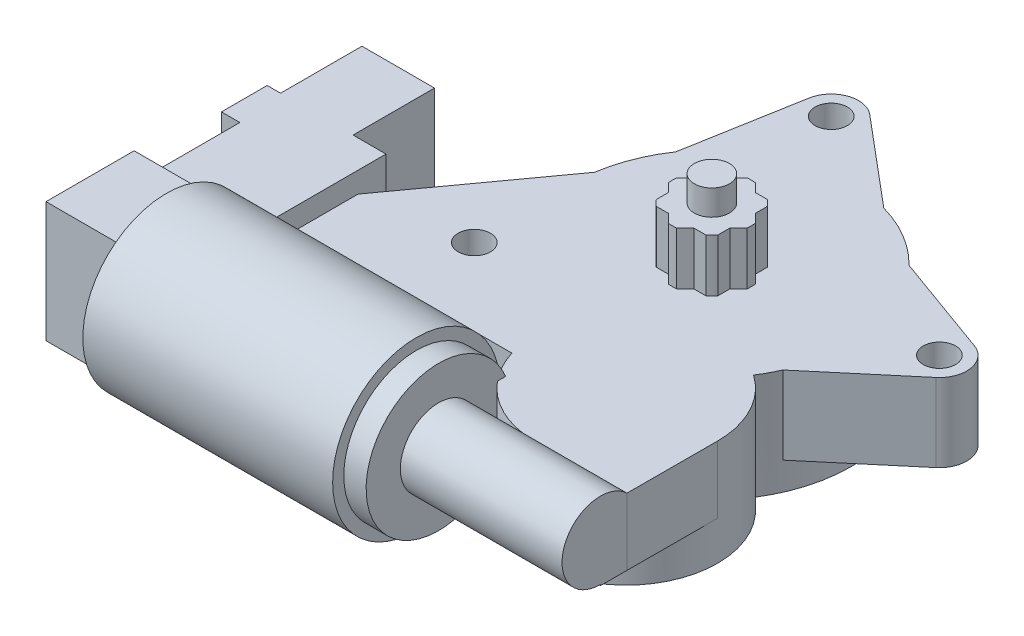
from build123d import *

# Parameters (mm, degrees)
SKETCH1_R                = 31.75
BOSS_EXTRUDE1_DEPTH      = 24.13
SKETCH2_R                = 20.828
BOSS_EXTRUDE2_DEPTH      = 24.13
SKETCH3_R                = 8.7249
BOSS_EXTRUDE3_DEPTH      = 35.56
BOSS_EXTRUDE3_DEPTH_BACK = 1.27
SKETCH4_R                = 16.51
BOSS_EXTRUDE4_DEPTH      = 5.08
SKETCH5_R                = 19.05
BOSS_EXTRUDE5_DEPTH      = 56.896
SKETCH6_W                = 20.066
SKETCH6_H                = 27.432
BOSS_EXTRUDE6_DEPTH      = 17.399
SKETCH7_W                = 22.86
SKETCH7_H                = 22.0218
BOSS_EXTRUDE7_DEPTH      = 20.32
SKETCH8_W                = 27.051
SKETCH8_H                = 22.0218
BOSS_EXTRUDE8_DEPTH      = 10.414
SKETCH9_W                = 16.51
SKETCH9_H                = 20.32
BOSS_EXTRUDE9_DEPTH      = 18.542
SKETCH10_W               = 13.208
SKETCH10_H               = 13.716
CUT_EXTRUDE1_DEPTH       = 18.542
BOSS_EXTRUDE10_START     = -6.35
BOSS_EXTRUDE10_DEPTH     = 17.78
BOSS_EXTRUDE11_DEPTH     = 15.24
SKETCH13_W               = 17.847333413
SKETCH13_H               = 6.050107252
BOSS_EXTRUDE12_DEPTH     = 15.24
SKETCH14_R               = 3.683
BOSS_EXTRUDE13_DEPTH     = 17.78
SKETCH15_R               = 3.683
CUT_EXTRUDE2_DEPTH       = 117.691841319
SKETCH16_R               = 4
BOSS_EXTRUDE14_DEPTH     = 17.78
SKETCH17_R               = 4
BOSS_EXTRUDE15_DEPTH     = 12


with BuildPart() as part:
    # Sketch1 → Boss-Extrude1 (new body)
    with BuildSketch(Plane(origin=(0, 0, 0), x_dir=(1, 0, 0), z_dir=(0, 1, 0))):
        with Locations(Location((0, 0, 0), (0, 0, 90))):
            Circle(SKETCH1_R)
    extrude(amount=BOSS_EXTRUDE1_DEPTH)

    # Sketch2 → Boss-Extrude2 (add)
    with BuildSketch(Plane(origin=(0, 24.13, 0), x_dir=(1, 0, 0), z_dir=(0, 1, 0))):
        with Locations((14.775728205, -34.29)):
            Circle(SKETCH2_R)
    extrude(amount=-BOSS_EXTRUDE2_DEPTH)

    # Sketch3 → Boss-Extrude3 (add, two sides)
    with BuildSketch(Plane(origin=(0, 0, 0), x_dir=(0, 0, -1), z_dir=(1, 0, 0))) as boss_extrude3_sk:
        with Locations((-60.96, 17.8435)):
            Circle(SKETCH3_R)
    extrude(amount=BOSS_EXTRUDE3_DEPTH)
    extrude(boss_extrude3_sk.sketch, amount=-BOSS_EXTRUDE3_DEPTH_BACK)

    # Sketch4 → Boss-Extrude4 (add)
    with BuildSketch(Plane.ZY.offset(1.27)):
        with Locations(Location((60.96, 17.8435, 0), (0, 0, 157.618661281))):
            Circle(SKETCH4_R)
    extrude(amount=BOSS_EXTRUDE4_DEPTH)

    # Sketch5 → Boss-Extrude5 (add)
    with BuildSketch(Plane.ZY.offset(6.35)):
        with Locations((60.96, 17.8435)):
            Circle(SKETCH5_R)
    extrude(amount=BOSS_EXTRUDE5_DEPTH)

    # Sketch6 → Boss-Extrude6 (add)
    with BuildSketch(Plane.ZY.offset(63.246)):
        with Locations((60.96, 17.8435)):
            Rectangle(SKETCH6_W, SKETCH6_H)
    extrude(amount=BOSS_EXTRUDE6_DEPTH)

    # Sketch7 → Boss-Extrude7 (add)
    with BuildSketch(Plane(origin=(0, 0, 50.927), x_dir=(-1, 0, 0), z_dir=(0, 0, -1))):
        with Locations((65.4558, 17.8435)):
            Rectangle(SKETCH7_W, SKETCH7_H)
    extrude(amount=BOSS_EXTRUDE7_DEPTH)

    # Sketch8 → Boss-Extrude8 (add)
    with BuildSketch(Plane(origin=(0, 0, 30.607), x_dir=(-1, 0, 0), z_dir=(0, 0, -1))):
        with Locations((67.5513, 17.8435)):
            Rectangle(SKETCH8_W, SKETCH8_H)
    extrude(amount=BOSS_EXTRUDE8_DEPTH)

    # Sketch9 → Boss-Extrude9 (add)
    with BuildSketch(Plane(origin=(0, 0, 20.193), x_dir=(-1, 0, 0), z_dir=(0, 0, -1))):
        with Locations((69.7738, 18.6944)):
            Rectangle(SKETCH9_W, SKETCH9_H)
    extrude(amount=BOSS_EXTRUDE9_DEPTH)

    # Sketch10 → Cut-Extrude1 (cut)
    with BuildSketch(Plane(origin=(0, 0, 1.651), x_dir=(-1, 0, 0), z_dir=(0, 0, -1))):
        with Locations((69.977, 16.8402)):
            Rectangle(SKETCH10_W, SKETCH10_H)
    extrude(amount=-CUT_EXTRUDE1_DEPTH, mode=Mode.SUBTRACT)

    # Sketch11 → Boss-Extrude10 (add)
    with BuildSketch(Plane.XZ.offset(BOSS_EXTRUDE10_START)):
        with BuildLine():
            Line((-31.398919365, -4.708541462), (-54.0258, 26.543))
            Line((-54.0258, 26.543), (-54.0258, 40.386))
            Line((-54.0258, 40.386), (-5.140204311, 40.386))
            ThreePointArc((-5.140204311, 40.386), (-5.994749346, 35.836882769), (-5.823485644, 31.211368361))
            ThreePointArc((-5.823485644, 31.211368361), (-25.863813313, 18.415364805), (-31.398919365, -4.708541462))
        make_face()
    extrude(amount=-BOSS_EXTRUDE10_DEPTH)

    # Sketch12 → Boss-Extrude11 (add)
    with BuildSketch(Plane(origin=(0, 24.13, 0), x_dir=(1, 0, 0), z_dir=(0, 1, 0))):
        with BuildLine():
            Line((35.60368127, -34.334216844), (35.56, -54.909892748))
            Line((35.56, -54.909892748), (17.712666587, -54.909892748))
            ThreePointArc((17.712666587, -54.909892748), (30.492983885, -47.956508622), (35.60368127, -34.334216844))
        make_face()
    extrude(amount=-BOSS_EXTRUDE11_DEPTH)

    # Sketch13 → Boss-Extrude12 (add)
    with BuildSketch(Plane.XZ.offset(-8.89)):
        with Locations((26.636333294, 57.934946374)):
            Rectangle(SKETCH13_W, SKETCH13_H)
    extrude(amount=-BOSS_EXTRUDE12_DEPTH)

    # Sketch14 → Boss-Extrude13 (add)
    with BuildSketch(Plane(origin=(0, 24.13, 0), x_dir=(1, 0, 0), z_dir=(0, 1, 0))):
        with BuildLine():
            Line((-26.194044188, 17.942534634), (-21.621621656, 43.757348716))
            ThreePointArc((-21.621621656, 43.757348716), (-17.617871268, 48.521350377), (-11.490249612, 47.436001661))
            Line((-11.490249612, 47.436001661), (8.579823912, 30.568760551))
            ThreePointArc((8.579823912, 30.568760551), (-10.836077898, 29.843624374), (-26.194044188, 17.942534634))
        make_face()
        with Locations(Location((-15.494, 42.672, 0), (0, 0, 270))):
            Circle(SKETCH14_R, mode=Mode.SUBTRACT)
        with BuildLine():
            Line((46.054149639, 13.727593162), (22.766210397, 22.130570805))
            ThreePointArc((22.766210397, 22.130570805), (31.252220413, 5.60010886), (29.034123834, -12.848429989))
            Line((29.034123834, -12.848429989), (47.955285562, 3.118028175))
            ThreePointArc((47.955285562, 3.118028175), (50.067435201, 8.971621337), (46.054149639, 13.727593162))
        make_face()
        with Locations(Location((43.942, 7.874, 0), (0, 0, 270))):
            Circle(SKETCH14_R, mode=Mode.SUBTRACT)
    extrude(amount=-BOSS_EXTRUDE13_DEPTH)

    # Sketch15 → Cut-Extrude2 (cut, through all)
    with BuildSketch(Plane(origin=(0, 24.13, 0), x_dir=(1, 0, 0), z_dir=(0, 1, 0))):
        with Locations(Location((-31.242, -22.86, 0), (0, 0, 270))):
            Circle(SKETCH15_R)
        with Locations(Location((43.942, 7.874, 0), (0, 0, 270))):
            Circle(SKETCH15_R)
        with Locations(Location((-15.494, 42.672, 0), (0, 0, 270))):
            Circle(SKETCH15_R)
    extrude(amount=-CUT_EXTRUDE2_DEPTH, mode=Mode.SUBTRACT)

    # Sketch16 → Boss-Extrude14 (add)
    with BuildSketch(Plane(origin=(0, 24.13, 0), x_dir=(1, 0, 0), z_dir=(0, 1, 0))):
        with Locations(Location((0, 0, 0), (0, 0, 270))):
            Circle(SKETCH16_R)
    extrude(amount=BOSS_EXTRUDE14_DEPTH)

    # Sketch17 → Boss-Extrude15 (add)
    with BuildSketch(Plane(origin=(0, 24.13, 0), x_dir=(1, 0, 0), z_dir=(0, 1, 0))):
        with BuildLine():
            Line((-2.899494937, -7), (-0.949747468, -8.949747468))
            ThreePointArc((-0.949747468, -8.949747468), (0, -9), (0.949747468, -8.949747468))
            Line((0.949747468, -8.949747468), (2.899494937, -7))
            Line((2.899494937, -7), (5.656854249, -7))
            ThreePointArc((5.656854249, -7), (6.363961031, -6.363961031), (7, -5.656854249))
            Line((7, -5.656854249), (7, -2.899494937))
            Line((7, -2.899494937), (8.949747468, -0.949747468))
            ThreePointArc((8.949747468, -0.949747468), (9, 0), (8.949747468, 0.949747468))
            Line((8.949747468, 0.949747468), (7, 2.899494937))
            Line((7, 2.899494937), (7, 5.656854249))
            ThreePointArc((7, 5.656854249), (6.363961031, 6.363961031), (5.656854249, 7))
            Line((5.656854249, 7), (2.899494937, 7))
            Line((2.899494937, 7), (0.949747468, 8.949747468))
            ThreePointArc((0.949747468, 8.949747468), (0, 9), (-0.949747468, 8.949747468))
            Line((-0.949747468, 8.949747468), (-2.899494937, 7))
            Line((-2.899494937, 7), (-5.656854249, 7))
            ThreePointArc((-5.656854249, 7), (-6.363961031, 6.363961031), (-7, 5.656854249))
            Line((-7, 5.656854249), (-7, 2.899494937))
            Line((-7, 2.899494937), (-8.949747468, 0.949747468))
            ThreePointArc((-8.949747468, 0.949747468), (-9, 0), (-8.949747468, -0.949747468))
            Line((-8.949747468, -0.949747468), (-7, -2.899494937))
            Line((-7, -2.899494937), (-7, -5.656854249))
            ThreePointArc((-7, -5.656854249), (-6.363961031, -6.363961031), (-5.656854249, -7))
            Line((-5.656854249, -7), (-2.899494937, -7))
        make_face()
        with Locations(Location((0, 0, 0), (0, 0, 270))):
            Circle(SKETCH17_R, mode=Mode.SUBTRACT)
    extrude(amount=BOSS_EXTRUDE15_DEPTH)


solid = part.part
